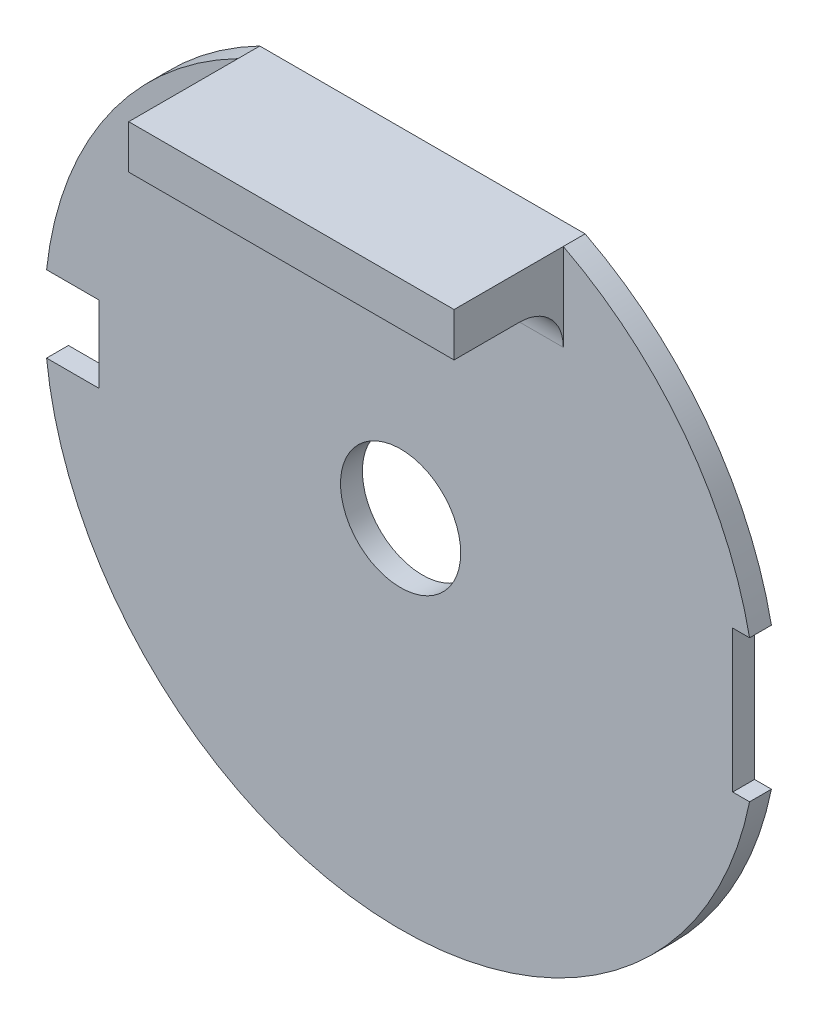
from build123d import *

# Parameters (mm, degrees)
SKETCH_1_R          = 2.75
EXTRUDE_1_DEPTH     = 1
SKETCH_2_W          = 5
SKETCH_2_H          = 3.5
SKETCH_2_W_2        = 2
SKETCH_2_H_2        = 6.5
CUT_EXTRUDE_1_DEPTH = 2
SKETCH_3_W          = 14.891608376
SKETCH_3_H          = 2
EXTRUDE_2_DEPTH     = 5
FILLET_1_R          = 2


with BuildPart() as part:
    # 草图1 → 凸台-拉伸1 (new body)
    with BuildSketch(Plane.XY):
        with BuildLine():
            Line((-7.445804188, 14.5), (7.445804188, 14.5))
            ThreePointArc((7.445804188, 14.5), (0, -16.3), (-7.445804188, 14.5))
        make_face()
        Circle(SKETCH_1_R, mode=Mode.SUBTRACT)
    extrude(amount=EXTRUDE_1_DEPTH)

    # 草图2 → 切除-拉伸1 (cut, through all)
    with BuildSketch(Plane.XY.offset(1)):
        with Locations((-16.3, 0)):
            Rectangle(SKETCH_2_W, SKETCH_2_H)
        with Locations((16.2, 0)):
            Rectangle(SKETCH_2_W_2, SKETCH_2_H_2)
    extrude(amount=-CUT_EXTRUDE_1_DEPTH, mode=Mode.SUBTRACT)

    # 草图3 → 凸台-拉伸2 (add)
    with BuildSketch(Plane.XY.offset(1)):
        with Locations((0, 13.5)):
            Rectangle(SKETCH_3_W, SKETCH_3_H)
    extrude(amount=EXTRUDE_2_DEPTH)

    # 圆角1
    fillet_1_edges = [part.edges().sort_by_distance(p)[0] for p in [
        (0, 12.5, 1),
    ]]
    fillet(fillet_1_edges, radius=FILLET_1_R)


solid = part.part
